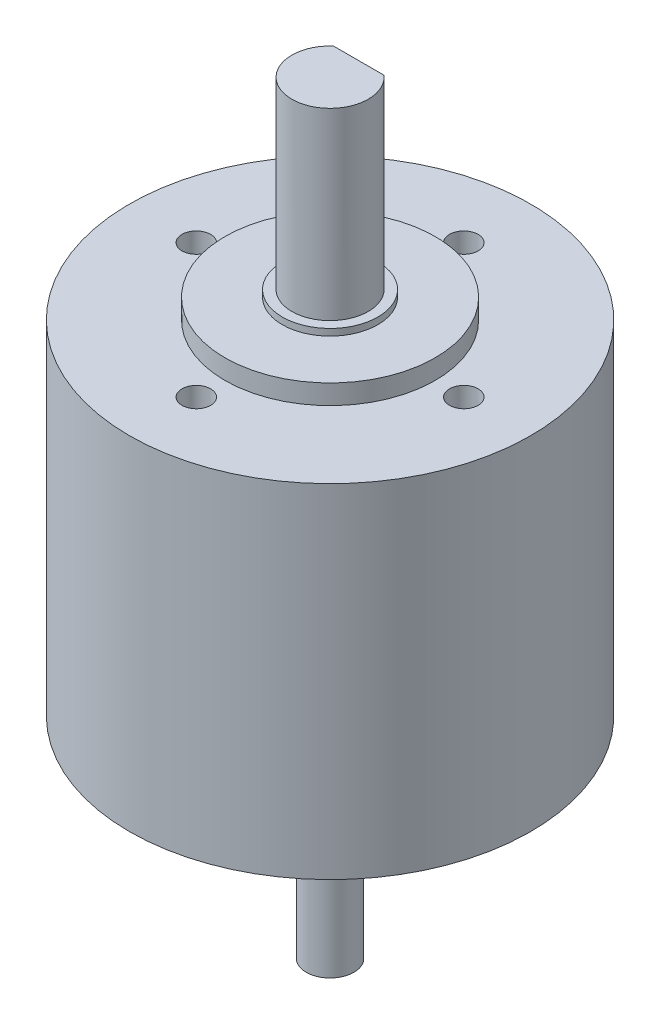
from build123d import *

# Parameters (mm, degrees)
SKETCH1_R           = 21
BOSS_EXTRUDE1_DEPTH = 17.9451
BOSS_EXTRUDE2_START = -17.9451
SKETCH2_R           = 11
BOSS_EXTRUDE2_DEPTH = 20.0025
SKETCH3_R           = 4
BOSS_EXTRUDE4_DEPTH = 19.9426
CUT_EXTRUDE1_DEPTH  = 15
SKETCH5_R           = 1.5
CUT_EXTRUDE2_DEPTH  = 4
SKETCH6_R           = 2.5
BOSS_EXTRUDE5_DEPTH = 19.9426
CUT_EXTRUDE3_DEPTH  = 16.9426
SKETCH9_R           = 5
BOSS_EXTRUDE6_DEPTH = 20.701


with BuildPart() as part:
    # Sketch1 → Boss-Extrude1 (new body, symmetric)
    with BuildSketch(Plane(origin=(0, 0, 0), x_dir=(1, 0, 0), z_dir=(0, 1, 0))):
        Circle(SKETCH1_R)
    extrude(amount=BOSS_EXTRUDE1_DEPTH, both=True)

    # Sketch2 → Boss-Extrude2 (add, symmetric)
    with BuildSketch(Plane(origin=(0, 17.9451, 0), x_dir=(1, 0, 0), z_dir=(0, 1, 0)).offset(BOSS_EXTRUDE2_START)):
        Circle(SKETCH2_R)
    extrude(amount=BOSS_EXTRUDE2_DEPTH, both=True)

    # Sketch3 → Boss-Extrude4 (add)
    with BuildSketch(Plane(origin=(0, 20.0025, 0), x_dir=(1, 0, 0), z_dir=(0, 1, 0))):
        Circle(SKETCH3_R)
    extrude(amount=BOSS_EXTRUDE4_DEPTH)

    # Sketch4 → Cut-Extrude1 (cut)
    with BuildSketch(Plane(origin=(0, 39.9451, 0), x_dir=(1, 0, 0), z_dir=(0, 1, 0))):
        with BuildLine():
            Line((-2.645751311, 3), (2.645751311, 3))
            ThreePointArc((2.645751311, 3), (0, 4), (-2.645751311, 3))
        make_face()
    extrude(amount=-CUT_EXTRUDE1_DEPTH, mode=Mode.SUBTRACT)

    # Sketch5 → Cut-Extrude2 (cut)
    with BuildSketch(Plane(origin=(0, 17.9451, 0), x_dir=(1, 0, 0), z_dir=(0, 1, 0))):
        with Locations((0, 14)):
            Circle(SKETCH5_R)
        with Locations((-14, 0)):
            Circle(SKETCH5_R)
        with Locations((0, -14)):
            Circle(SKETCH5_R)
        with Locations((14, 0)):
            Circle(SKETCH5_R)
    extrude(amount=-CUT_EXTRUDE2_DEPTH, mode=Mode.SUBTRACT)

    # Sketch6 → Boss-Extrude5 (add)
    with BuildSketch(Plane.XZ.offset(20.0025)):
        Circle(SKETCH6_R)
    extrude(amount=BOSS_EXTRUDE5_DEPTH)

    # Sketch7 → Cut-Extrude3 (cut)
    with BuildSketch(Plane.XZ.offset(39.9451)):
        with BuildLine():
            Line((-2, -1.5), (2, -1.5))
            ThreePointArc((2, -1.5), (0, -2.5), (-2, -1.5))
        make_face()
    extrude(amount=-CUT_EXTRUDE3_DEPTH, mode=Mode.SUBTRACT)

    # Sketch9 → Boss-Extrude6 (add, symmetric)
    with BuildSketch(Plane(origin=(0, 0, 0), x_dir=(1, 0, 0), z_dir=(0, 1, 0))):
        Circle(SKETCH9_R)
    extrude(amount=BOSS_EXTRUDE6_DEPTH, both=True)


solid = part.part
